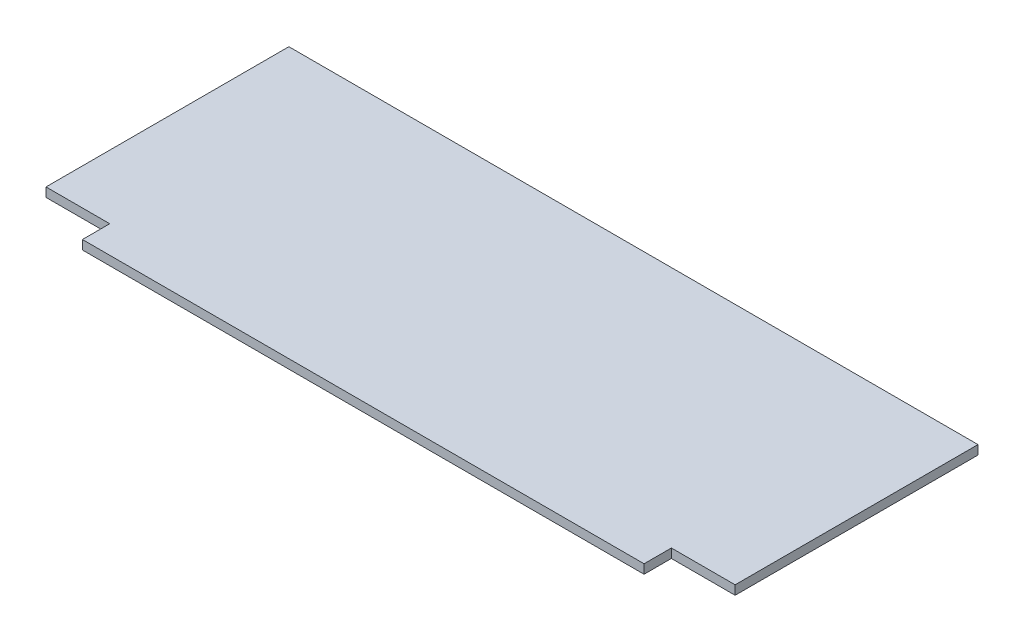
from build123d import *

# Parameters (mm, degrees)
EXTRUDE1_DEPTH = 3


with BuildPart() as part:
    # Sketch1 → Extrude1 (new body)
    with BuildSketch(Plane(origin=(0, 0, 0), x_dir=(1, 0, 0), z_dir=(0, 1, 0))):
        Polygon((-92.5, -35.5), (-92.5, -44.5), (92.5, -44.5), (92.5, -35.5), (113.5, -35.5), (113.5, 44.5), (-113.5, 44.5), (-113.5, -35.5), align=None)
    extrude(amount=EXTRUDE1_DEPTH)


solid = part.part
